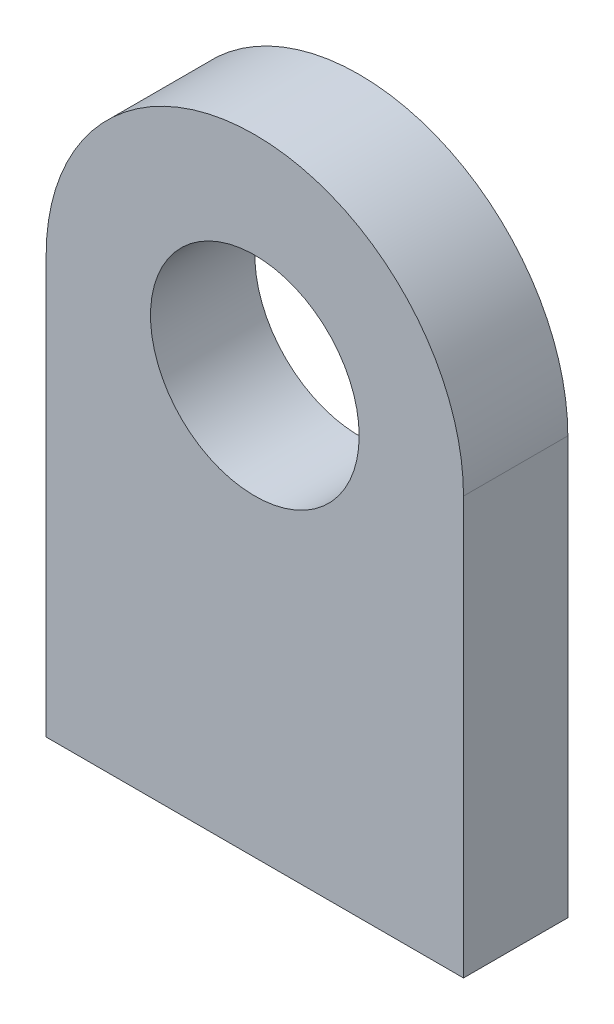
from build123d import *

# Parameters (mm, degrees)
SKETCH1_R           = 3.175
BOSS_EXTRUDE1_DEPTH = 3.175


with BuildPart() as part:
    # Sketch1 → Boss-Extrude1 (new body)
    with BuildSketch(Plane.XY):
        with BuildLine():
            Line((6.35, -6.35), (-6.35, -6.35))
            Line((-6.35, -6.35), (-6.35, 6.35))
            ThreePointArc((-6.35, 6.35), (0, 12.7), (6.35, 6.35))
            Line((6.35, 6.35), (6.35, -6.35))
        make_face()
        with Locations((0, 6.35)):
            Circle(SKETCH1_R, mode=Mode.SUBTRACT)
    extrude(amount=BOSS_EXTRUDE1_DEPTH)


solid = part.part
